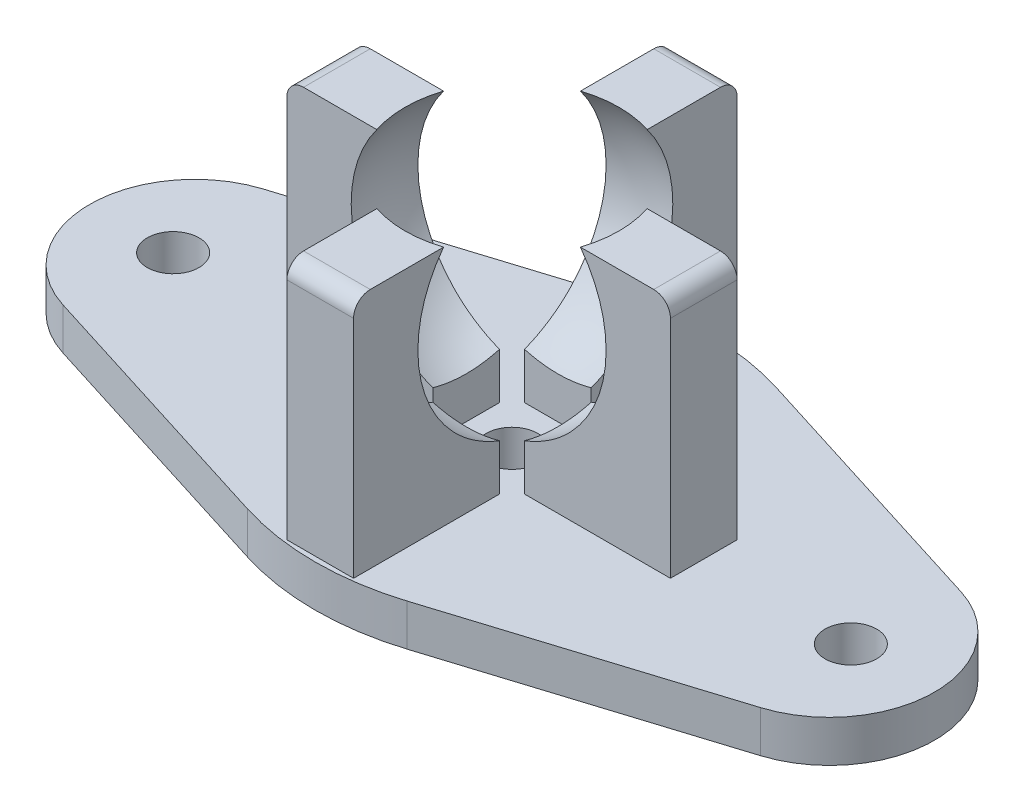
from build123d import *

# Parameters (mm, degrees)
BOSS_EXTRUDE1_DEPTH = 2.5
FILLET1_R           = 16
FILLET2_R           = 6.3
BOSS_EXTRUDE2_DEPTH = 14.5
FILLET3_R           = 1
SKETCH5_W           = 5.5
SKETCH5_H           = 5.5
CUT_EXTRUDE1_DEPTH  = 31.959805
SKETCH6_R           = 1.55
CUT_EXTRUDE2_DEPTH  = 2.5
SKETCH7_R           = 1.55
CUT_EXTRUDE3_DEPTH  = 2.5


with BuildPart() as part:
    # Sketch1 → Boss-Extrude1 (new body)
    with BuildSketch(Plane(origin=(0, 0, 0), x_dir=(1, 0, 0), z_dir=(0, 1, 0))):
        Polygon((0, 12.577166077), (-40.072620247, 0), (0, -12.577166077), (40.072620247, 0), align=None)
    extrude(amount=BOSS_EXTRUDE1_DEPTH)

    # Fillet1
    fillet1_edges = [part.edges().sort_by_distance(p)[0] for p in [
        (0, 1.25, 12.577166077),
        (0, 1.25, -12.577166077),
    ]]
    fillet(fillet1_edges, radius=FILLET1_R)

    # Fillet2
    fillet2_edges = [part.edges().sort_by_distance(p)[0] for p in [
        (40.072620247, 1.25, 0),
        (-40.072620247, 1.25, 0),
    ]]
    fillet(fillet2_edges, radius=FILLET2_R)

    # Sketch2 → Boss-Extrude2 (add)
    with BuildSketch(Plane(origin=(0, 2.5, 0), x_dir=(1, 0, 0), z_dir=(0, 1, 0))):
        Polygon((2, 2), (11.5, 2), (11.5, -2), (2, -2), (2, -11.5), (-2, -11.5), (-2, -2), (-11.5, -2), (-11.5, 2), (-2, 2), (-2, 11.5), (2, 11.5), align=None)
    extrude(amount=BOSS_EXTRUDE2_DEPTH)

    # Sketch3 → Cut-Revolve1 (revolve, cut)
    with BuildSketch(Plane.XY):
        with BuildLine():
            ThreePointArc((0, 4.5), (7.9, 12.4), (0, 20.3))
            Line((0, 20.3), (0, 4.5))
        make_face()
    revolve(axis=Axis((0, 20.3, 0), (0, -1, 0)), mode=Mode.SUBTRACT)

    # Fillet3
    fillet3_edges = [part.edges().sort_by_distance(p)[0] for p in [
        (-11.5, 17, 0),
        (0, 17, 11.5),
        (11.5, 17, 0),
        (0, 17, -11.5),
    ]]
    fillet(fillet3_edges, radius=FILLET3_R)

    # Sketch5 → Cut-Extrude1 (cut)
    with BuildSketch(Plane(origin=(0, 2.5, 0), x_dir=(1, 0, 0), z_dir=(0, 1, 0))):
        Rectangle(SKETCH5_W, SKETCH5_H)
    extrude(amount=CUT_EXTRUDE1_DEPTH, mode=Mode.SUBTRACT)

    # Sketch6 → Cut-Extrude2 (cut)
    with BuildSketch(Plane(origin=(0, 2.5, 0), x_dir=(1, 0, 0), z_dir=(0, 1, 0))):
        Circle(SKETCH6_R)
    extrude(amount=-CUT_EXTRUDE2_DEPTH, mode=Mode.SUBTRACT)

    # Sketch7 → Cut-Extrude3 (cut)
    with BuildSketch(Plane(origin=(0, 2.5, 0), x_dir=(1, 0, 0), z_dir=(0, 1, 0))):
        with Locations((20.32, 0)):
            Circle(SKETCH7_R)
        with Locations((-20.32, 0)):
            Circle(SKETCH7_R)
    extrude(amount=-CUT_EXTRUDE3_DEPTH, mode=Mode.SUBTRACT)


solid = part.part
